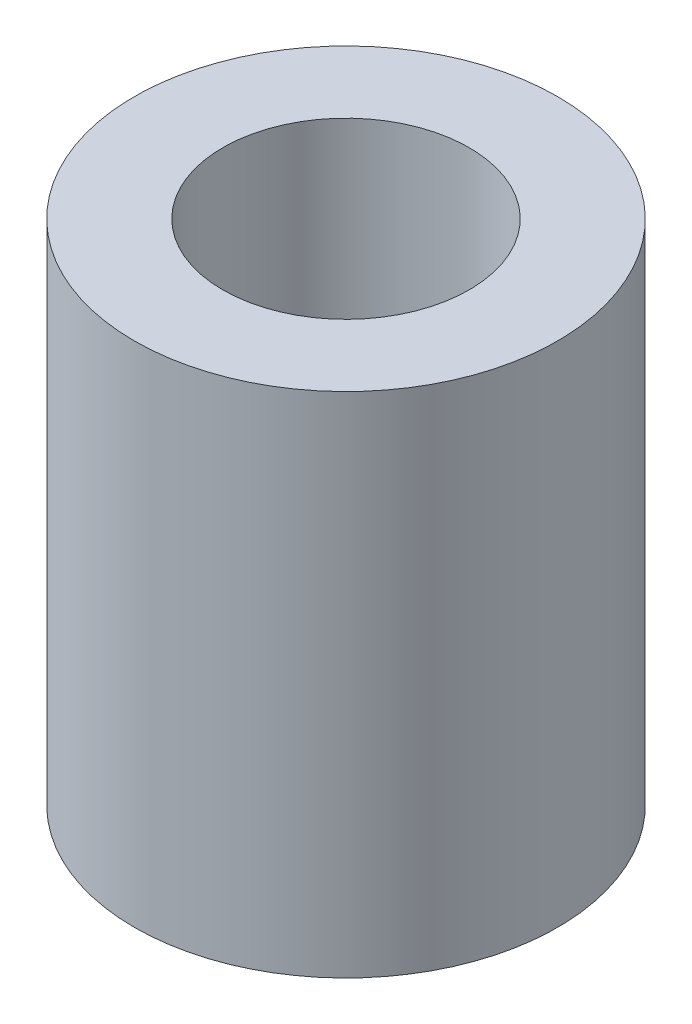
from build123d import *

# Parameters (mm, degrees)
SKETCH1_R           = 12.5
SKETCH1_R_2         = 7.277545571
BOSS_EXTRUDE1_DEPTH = 30


with BuildPart() as part:
    # Sketch1 → Boss-Extrude1 (new body)
    with BuildSketch(Plane(origin=(0, 0, 0), x_dir=(1, 0, 0), z_dir=(0, 1, 0))):
        Circle(SKETCH1_R)
        Circle(SKETCH1_R_2, mode=Mode.SUBTRACT)
    extrude(amount=BOSS_EXTRUDE1_DEPTH)


solid = part.part
